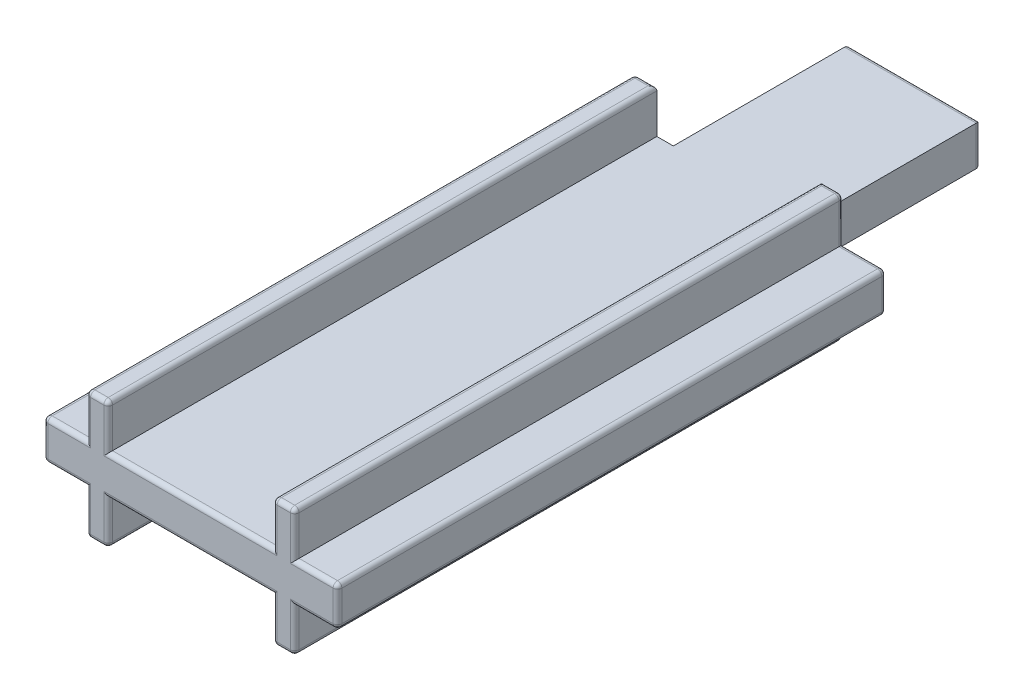
from build123d import *

# Parameters (mm, degrees)
AUFSATZ_LINEAR_AUSTRAGEN1_DEPTH = 25
SKIZZE2_W                       = 6
SKIZZE2_H                       = 1.8
AUFSATZ_LINEAR_AUSTRAGEN2_DEPTH = 8
VERRUNDUNG1_R                   = 0.2


with BuildPart() as part:
    # Skizze1 → Aufsatz-Linear austragen1 (new body)
    with BuildSketch(Plane.XY):
        Polygon((-4.75, 0.9), (-6.7, 0.9), (-6.7, -0.9), (-4.75, -0.9), (-4.75, -2.9), (-3.75, -2.9), (-3.75, -0.9), (3.75, -0.9), (3.75, -2.9), (4.75, -2.9), (4.75, -0.9), (6.7, -0.9), (6.7, 0.9), (4.75, 0.9), (4.75, 2.9), (3.75, 2.9), (3.75, 0.9), (-3.75, 0.9), (-3.75, 2.9), (-4.75, 2.9), align=None)
    extrude(amount=AUFSATZ_LINEAR_AUSTRAGEN1_DEPTH)

    # Skizze2 → Aufsatz-Linear austragen2 (add)
    with BuildSketch(Plane(origin=(0, 0, 0), x_dir=(-1, 0, 0), z_dir=(0, 0, -1))):
        Rectangle(SKIZZE2_W, SKIZZE2_H)
    extrude(amount=AUFSATZ_LINEAR_AUSTRAGEN2_DEPTH)

    # Verrundung1
    verrundung1_edges = [part.edges().sort_by_distance(p)[0] for p in [
        (-4.75, -1.9, 25),
        (-4.25, -2.9, 25),
        (-5.725, 0.9, 0),
        (-4.75, 1.9, 0),
        (-4.25, 2.9, 0),
        (-3.75, -1.9, 25),
        (4.25, 2.9, 0),
        (4.75, 1.9, 0),
        (5.725, 0.9, 0),
        (6.7, 0, 0),
        (5.725, -0.9, 0),
        (4.75, -1.9, 0),
        (4.25, -2.9, 0),
        (0, -0.9, 25),
        (-4.25, -2.9, 0),
        (-4.75, -1.9, 0),
        (-5.725, -0.9, 0),
        (-6.7, 0, 0),
        (3.75, -1.9, 25),
        (4.25, -2.9, 25),
        (-6.7, 0.9, 12.5),
        (-4.75, 2.9, 12.5),
        (-3.75, 2.9, 12.5),
        (3.75, 2.9, 12.5),
        (4.75, 2.9, 12.5),
        (6.7, 0.9, 12.5),
        (6.7, -0.9, 12.5),
        (4.75, -2.9, 12.5),
        (3.75, -2.9, 12.5),
        (-3.75, -2.9, 12.5),
        (-4.75, -2.9, 12.5),
        (-6.7, -0.9, 12.5),
        (4.75, -1.9, 25),
        (5.725, -0.9, 25),
        (6.7, 0, 25),
        (5.725, 0.9, 25),
        (-6.7, 0, 25),
        (4.75, 1.9, 25),
        (4.25, 2.9, 25),
        (3, 0, -8),
        (3.75, 1.9, 25),
        (0, -0.9, -8),
        (-3, 0, -8),
        (0, 0.9, -8),
        (0, 0.9, 25),
        (-3.75, 1.9, 25),
        (-4.25, 2.9, 25),
        (-4.75, 1.9, 25),
        (-5.725, 0.9, 25),
        (-5.725, -0.9, 25),
    ]]
    fillet(verrundung1_edges, radius=VERRUNDUNG1_R)


solid = part.part
